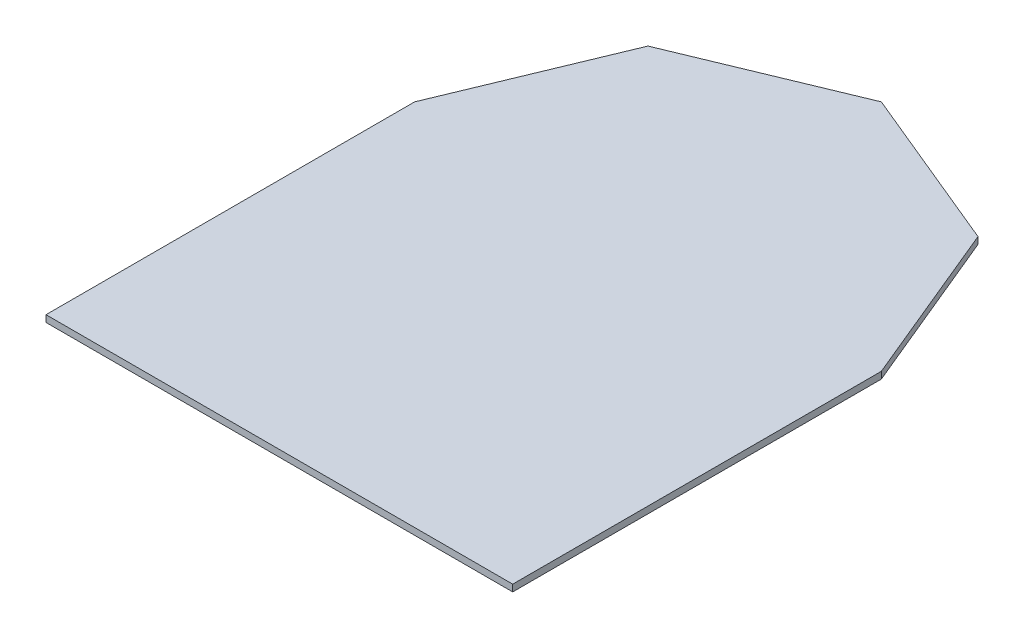
from build123d import *

# Parameters (mm, degrees)
BOSS_EXTRUDE1_DEPTH = 2.5


with BuildPart() as part:
    # Sketch1 → Boss-Extrude1 (new body)
    with BuildSketch(Plane(origin=(0, 0, 0), x_dir=(1, 0, 0), z_dir=(0, 1, 0))):
        Polygon((0, 0), (172.5, 0), (172.5, 136.25), (147.237959877, 197.237959877), (86.25, 222.5), (25.262040123, 197.237959877), (0, 136.25), align=None)
    extrude(amount=BOSS_EXTRUDE1_DEPTH)


solid = part.part
